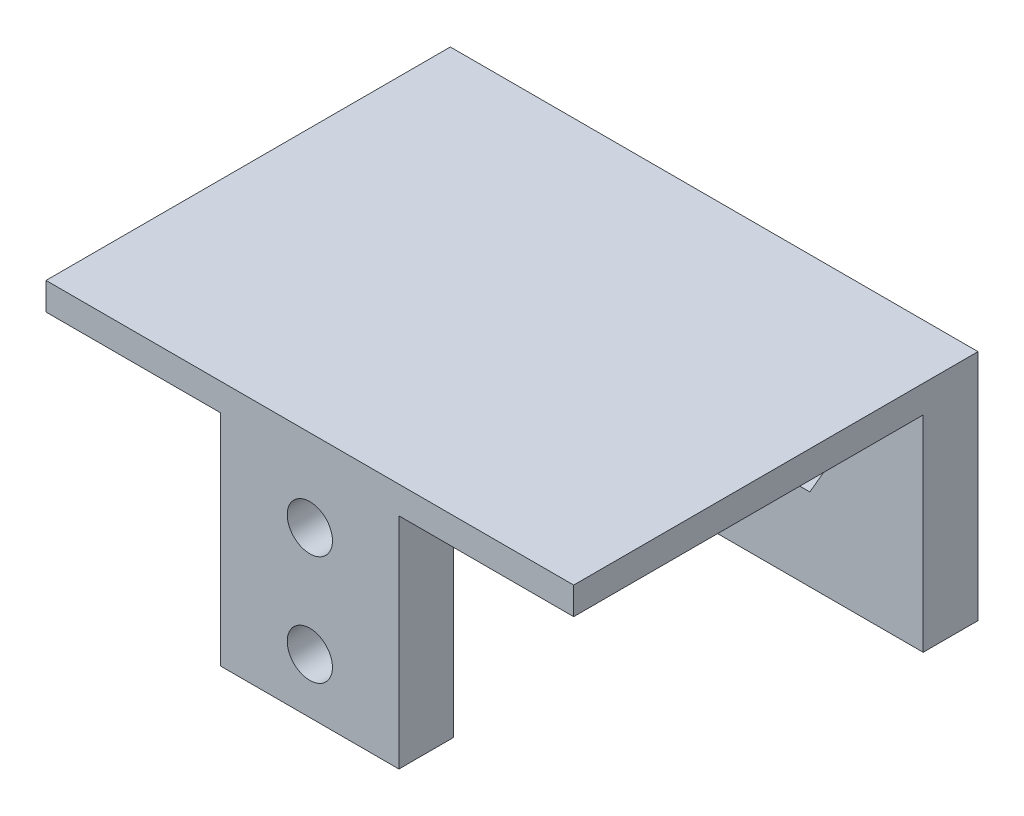
from build123d import *

# Parameters (mm, degrees)
SKETCH1_W           = 38.5
SKETCH1_H           = 29.5
BOSS_EXTRUDE1_DEPTH = 2
SKETCH2_W           = 13
SKETCH2_H           = 16
BOSS_EXTRUDE2_DEPTH = 4
SKETCH3_W           = 38.5
SKETCH3_H           = 4
BOSS_EXTRUDE3_DEPTH = 15
SKETCH4_R           = 1.65
CUT_EXTRUDE1_DEPTH  = 15
CUT_EXTRUDE2_DEPTH  = 2.5
SKETCH6_R           = 1.65
CUT_EXTRUDE3_DEPTH  = 2.5


with BuildPart() as part:
    # Sketch1 → Boss-Extrude1 (new body)
    with BuildSketch(Plane(origin=(0, 0, 0), x_dir=(1, 0, 0), z_dir=(0, 1, 0))):
        with Locations((19.25, -14.75)):
            Rectangle(SKETCH1_W, SKETCH1_H)
    extrude(amount=BOSS_EXTRUDE1_DEPTH)

    # Sketch2 → Boss-Extrude2 (add)
    with BuildSketch(Plane.XY.offset(29.5)):
        with Locations((19.25, -8)):
            Rectangle(SKETCH2_W, SKETCH2_H)
    extrude(amount=-BOSS_EXTRUDE2_DEPTH)

    # Sketch3 → Boss-Extrude3 (add)
    with BuildSketch(Plane.XZ):
        with Locations((19.25, 2)):
            Rectangle(SKETCH3_W, SKETCH3_H)
    extrude(amount=BOSS_EXTRUDE3_DEPTH)

    # Sketch4 → Cut-Extrude1 (cut)
    with BuildSketch(Plane.XY.offset(29.5)):
        with Locations((19.25, -4)):
            Circle(SKETCH4_R)
        with Locations((19.25, -12)):
            Circle(SKETCH4_R)
    extrude(amount=-CUT_EXTRUDE1_DEPTH, mode=Mode.SUBTRACT)

    # Sketch5 → Cut-Extrude2 (cut)
    with BuildSketch(Plane.XY.offset(4)):
        Polygon((11.732050808, -9), (13.464101615, -6), (11.732050808, -3), (8.267949192, -3), (6.535898385, -6), (8.267949192, -9), align=None)
        Polygon((30.232050808, -9), (31.964101615, -6), (30.232050808, -3), (26.767949192, -3), (25.035898385, -6), (26.767949192, -9), align=None)
    extrude(amount=-CUT_EXTRUDE2_DEPTH, mode=Mode.SUBTRACT)

    # Sketch6 → Cut-Extrude3 (cut)
    with BuildSketch(Plane.XY.offset(1.5)):
        with Locations((10, -6)):
            Circle(SKETCH6_R)
        with Locations((28.5, -6)):
            Circle(SKETCH6_R)
    extrude(amount=-CUT_EXTRUDE3_DEPTH, mode=Mode.SUBTRACT)


solid = part.part
